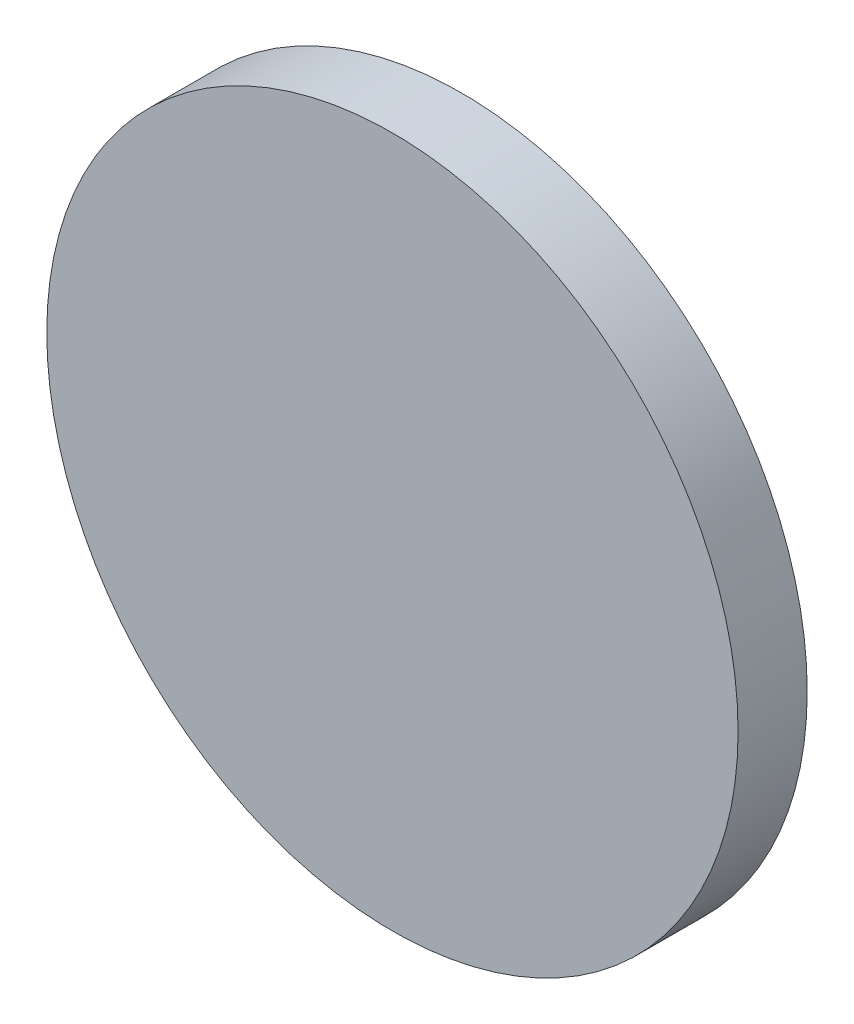
from build123d import *

# Parameters (mm, degrees)
SKETCH1_R           = 15
BOSS_EXTRUDE1_DEPTH = 3


with BuildPart() as part:
    # Sketch1 → Boss-Extrude1 (new body)
    with BuildSketch(Plane.XY):
        Circle(SKETCH1_R)
    extrude(amount=BOSS_EXTRUDE1_DEPTH)


solid = part.part
